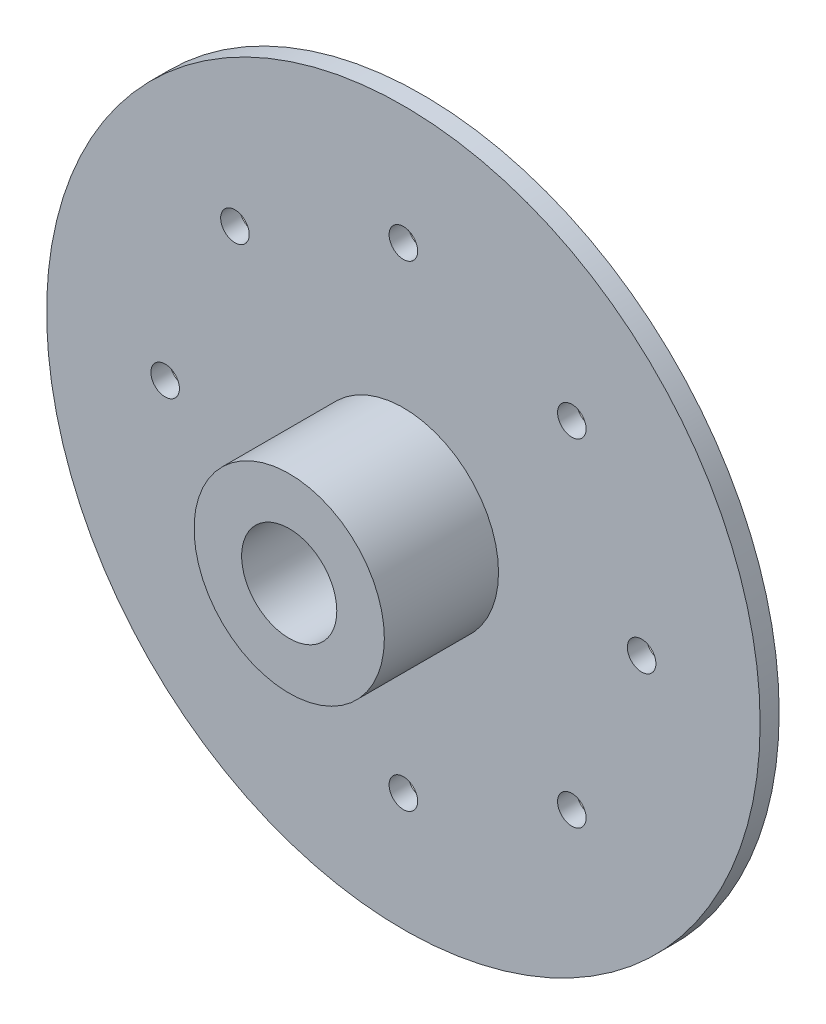
from build123d import *

# Parameters (mm, degrees)
SKETCH1_R           = 37.5
BOSS_EXTRUDE1_DEPTH = 2
SKETCH2_R           = 1.5
CUT_EXTRUDE1_DEPTH  = 10
CIRPATTERN1_COUNT   = 8
SKETCH3_R           = 10
SKETCH3_R_2         = 5
BOSS_EXTRUDE2_DEPTH = 12


with BuildPart() as part:
    # Sketch1 → Boss-Extrude1 (new body)
    with BuildSketch(Plane.XY):
        Circle(SKETCH1_R)
    extrude(amount=BOSS_EXTRUDE1_DEPTH)

    # Sketch2 → Cut-Extrude1 (cut)
    with BuildSketch(Plane.XY.offset(2)):
        with Locations((0, 25)):
            Circle(SKETCH2_R)
    cut_extrude1 = extrude(amount=-CUT_EXTRUDE1_DEPTH, mode=Mode.SUBTRACT)

    # CirPattern1: Cut-Extrude1 ×8 about axis
    cirpattern1_axis = Axis((0, -0.040064103, 0), (0, 0, 1))
    for i in range(1, CIRPATTERN1_COUNT):
        add(cut_extrude1.rotate(cirpattern1_axis, i * 360 / CIRPATTERN1_COUNT), mode=Mode.SUBTRACT)

    # Sketch3 → Boss-Extrude2 (add)
    with BuildSketch(Plane.XY.offset(2)):
        Circle(SKETCH3_R)
        Circle(SKETCH3_R_2, mode=Mode.SUBTRACT)
    extrude(amount=BOSS_EXTRUDE2_DEPTH)


solid = part.part
